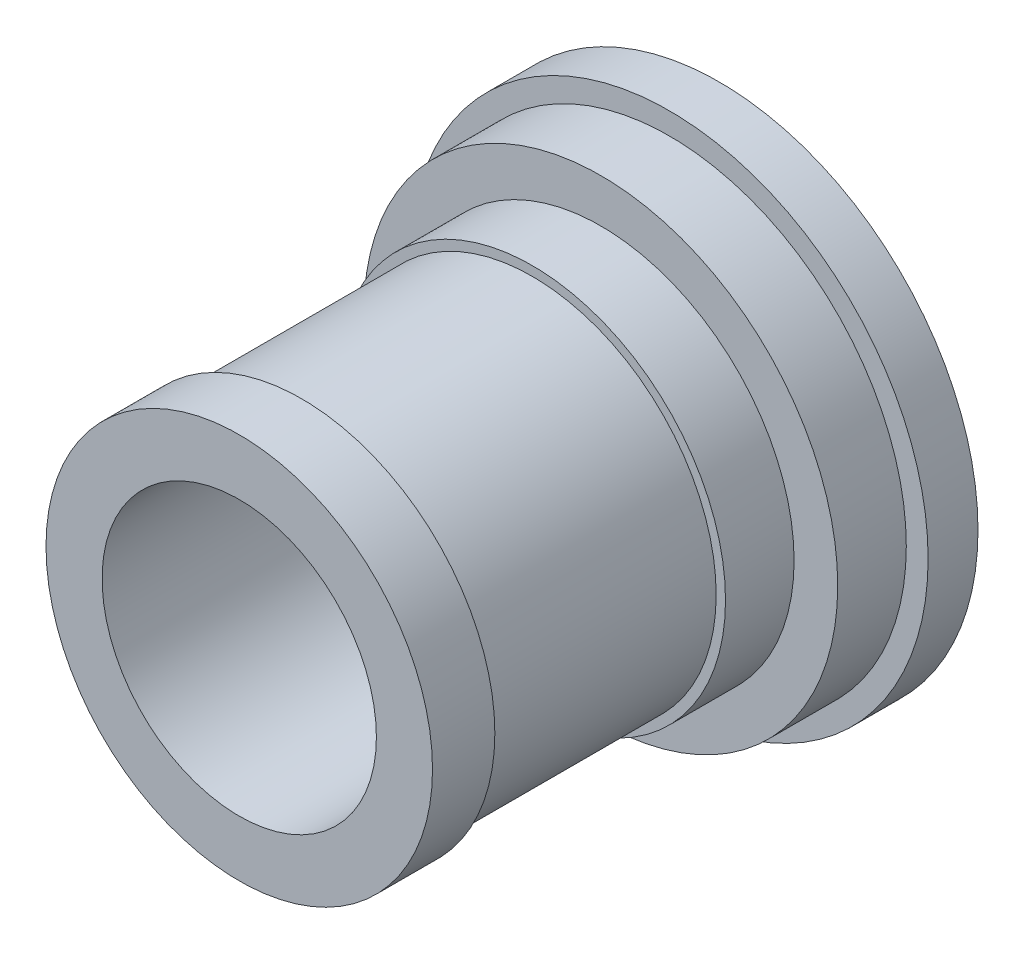
from build123d import *


with BuildPart() as part:
    # Sketch1 → Revolve1 (revolve)
    with BuildSketch(Plane(origin=(0, 0, 0), x_dir=(1, 0, 0), z_dir=(0, 1, 0))):
        Polygon((22, 0), (31, 0), (31, 10), (29.5, 10), (29.5, 47), (31, 47), (31, 58), (38, 58), (38, 69), (41.5, 69), (41.5, 77), (22, 77), align=None)
    revolve(axis=Axis((0, 0, 0), (0, 0, -1)))


solid = part.part
